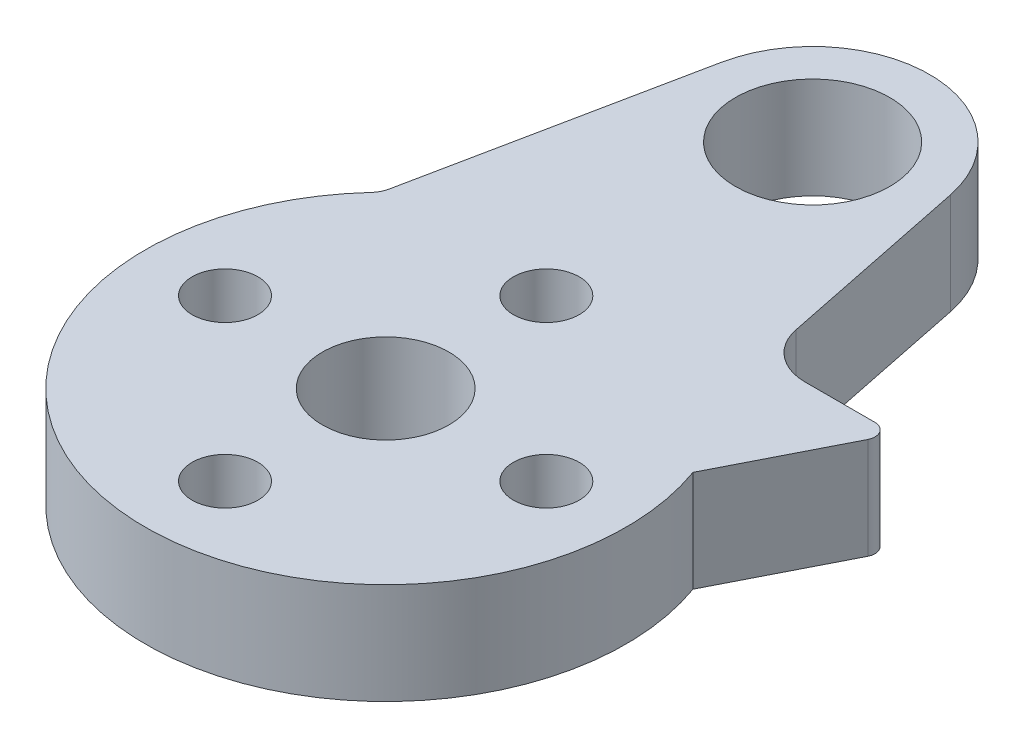
from build123d import *

# Parameters (mm, degrees)
SKETCH1_R           = 3.05
SKETCH1_R_2         = 2.5
BOSS_EXTRUDE1_DEPTH = 4
SKETCH2_R           = 1.3
CUT_EXTRUDE1_DEPTH  = 4
BOSS_EXTRUDE2_DEPTH = 4
BOSS_EXTRUDE3_DEPTH = 4
FILLET1_R           = 1
FILLET9_R           = 0.5
FILLET10_R          = 2


with BuildPart() as part:
    # Sketch1 → Boss-Extrude1 (new body)
    with BuildSketch(Plane(origin=(0, 0, 0), x_dir=(1, 0, 0), z_dir=(0, 1, 0))):
        with BuildLine():
            Line((-4.531642246, 17.7995776), (-7.838367177, 1.6))
            ThreePointArc((-7.838367177, 1.6), (0, -8), (7.838367177, 1.6))
            Line((7.838367177, 1.6), (4.531642246, 17.7995776))
            ThreePointArc((4.531642246, 17.7995776), (0, 21.499648), (-4.531642246, 17.7995776))
        make_face()
        with Locations((0, 16.87456)):
            Circle(SKETCH1_R, mode=Mode.SUBTRACT)
        Circle(SKETCH1_R_2, mode=Mode.SUBTRACT)
    extrude(amount=BOSS_EXTRUDE1_DEPTH)

    # Sketch2 → Cut-Extrude1 (cut)
    with BuildSketch(Plane(origin=(0, 4, 0), x_dir=(1, 0, 0), z_dir=(0, 1, 0))):
        with Locations((0, 6.35)):
            Circle(SKETCH2_R)
        with Locations((6.35, 0)):
            Circle(SKETCH2_R)
        with Locations((0, -6.35)):
            Circle(SKETCH2_R)
        with Locations((-6.35, 0)):
            Circle(SKETCH2_R)
    extrude(amount=-CUT_EXTRUDE1_DEPTH, mode=Mode.SUBTRACT)

    # Sketch3 → Boss-Extrude2 (add)
    with BuildSketch(Plane(origin=(0, 4, 0), x_dir=(1, 0, 0), z_dir=(0, 1, 0))):
        with BuildLine():
            Line((-7.838367177, 1.6), (-6.8136721, 6.619960159))
            ThreePointArc((-6.8136721, 6.619960159), (0, -9.5), (6.8136721, 6.619960159))
            Line((6.8136721, 6.619960159), (7.838367177, 1.6))
            ThreePointArc((7.838367177, 1.6), (0, -8), (-7.838367177, 1.6))
        make_face()
    extrude(amount=-BOSS_EXTRUDE2_DEPTH)

    # Sketch4 → Boss-Extrude3 (add)
    with BuildSketch(Plane(origin=(0, 4, 0), x_dir=(1, 0, 0), z_dir=(0, 1, 0))):
        with BuildLine():
            Line((10.392304845, 8.510381451), (6.42779147, 8.510381451))
            Line((6.42779147, 8.510381451), (6.8136721, 6.619960159))
            Line((6.8136721, 6.619960159), (1.793071605, 1.742094779))
            ThreePointArc((1.793071605, 1.742094779), (1.994303817, 1.507565019), (2.165063509, 1.25))
            Line((2.165063509, 1.25), (5.073143183, 2.928980582))
            Line((5.073143183, 2.928980582), (8.943807158, 3.20286021))
            Line((8.943807158, 3.20286021), (10.361060865, 5.990375719))
            Line((10.361060865, 5.990375719), (11.642304845, 8.510381451))
            Line((11.642304845, 8.510381451), (10.392304845, 8.510381451))
        make_face()
    extrude(amount=-BOSS_EXTRUDE3_DEPTH)

    # Fillet1
    fillet1_edges = [part.edges().sort_by_distance(p)[0] for p in [
        (-6.8136721, 2, -6.619960159),
    ]]
    fillet(fillet1_edges, radius=FILLET1_R)

    # Fillet9
    fillet9_edges = [part.edges().sort_by_distance(p)[0] for p in [
        (11.642304845, 2, -8.510381451),
    ]]
    fillet(fillet9_edges, radius=FILLET9_R)

    # Fillet10
    fillet10_edges = [part.edges().sort_by_distance(p)[0] for p in [
        (6.42779147, 2, -8.510381451),
    ]]
    fillet(fillet10_edges, radius=FILLET10_R)


solid = part.part
